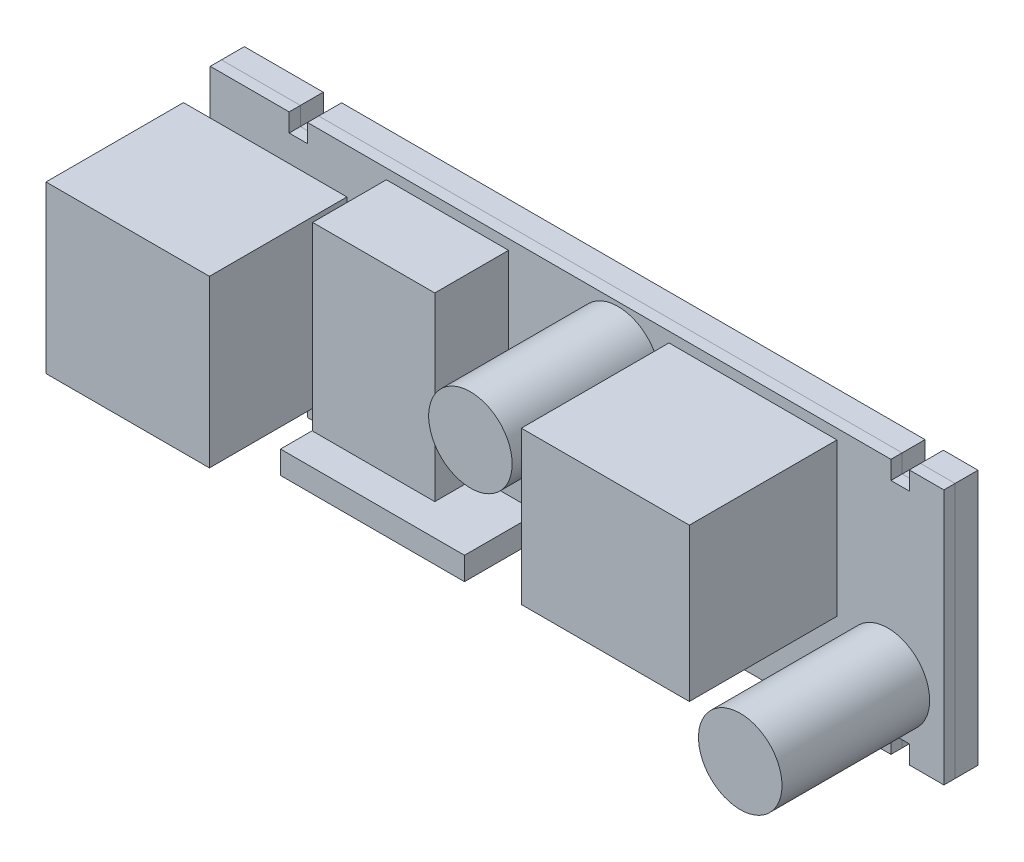
from build123d import *

# Parameters (mm, degrees)
SKETCH1_R                 = 1.375
BOSS_BOARDTHK_DEPTH       = 1.1
SKETCH1_3_R               = 1.375
BOSS_LOWERCLEARANCE_DEPTH = 2.25
SKETCH2_R                 = 4.1
BOSS_EXTRUDE3_DEPTH       = 14.5
BOSS_EXTRUDE3_2_DEPTH     = 14.5
SKETCH2_W                 = 16.5
SKETCH2_H                 = 15
BOSS_EXTRUDE3_3_DEPTH     = 14.5
SKETCH2_4_W               = 12
SKETCH2_4_H               = 17.75
SKETCH2_4_W_2             = 18.07
SKETCH2_4_H_2             = 2.25
BOSS_EXTRUDE4_DEPTH       = 7.25
SKETCH2_5_W               = 16.05
SKETCH2_5_H               = 16.3
BOSS_EXTRUDE5_DEPTH       = 13.5


with BuildPart() as part:
    # Sketch1 → Boss-BoardThk (new body)
    with BuildSketch(Plane.XY):
        Polygon((-36.675, 12.55), (-36.675, -12.55), (-28.925, -12.55), (-28.925, -10.75), (-27.125, -10.75), (-27.125, -12.55), (30.175, -12.55), (30.175, -10.75), (31.975, -10.75), (31.975, -12.55), (35.375, -12.55), (35.375, 12.55), (31.975, 12.55), (31.975, 10.75), (30.175, 10.75), (30.175, 12.55), (-27.125, 12.55), (-27.125, 10.75), (-28.925, 10.75), (-28.925, 12.55), align=None)
        Circle(SKETCH1_R, mode=Mode.SUBTRACT)
    extrude(amount=BOSS_BOARDTHK_DEPTH)

    # Sketch2_4 → Boss-Extrude4 (add)
    with BuildSketch(Plane.XY.offset(1.1)):
        with Locations((-13.375, 2.675)):
            Rectangle(SKETCH2_4_W, SKETCH2_4_H)
        with Locations((-13.49, -10.425)):
            Rectangle(SKETCH2_4_W_2, SKETCH2_4_H_2)
    extrude(amount=BOSS_EXTRUDE4_DEPTH)

    # Sketch2_5 → Boss-Extrude5 (add)
    with BuildSketch(Plane.XY.offset(1.1)):
        with Locations((-31.28, 0)):
            Rectangle(SKETCH2_5_W, SKETCH2_5_H)
    extrude(amount=BOSS_EXTRUDE5_DEPTH)


with BuildPart() as body_2:
    # Sketch1_3 → Boss-LowerClearance (new body)
    with BuildSketch(Plane.XY):
        Polygon((-36.675, 12.55), (-36.675, -12.55), (-28.925, -12.55), (-28.925, -10.75), (-27.125, -10.75), (-27.125, -12.55), (30.175, -12.55), (30.175, -10.75), (31.975, -10.75), (31.975, -12.55), (35.375, -12.55), (35.375, 12.55), (31.975, 12.55), (31.975, 10.75), (30.175, 10.75), (30.175, 12.55), (-27.125, 12.55), (-27.125, 10.75), (-28.925, 10.75), (-28.925, 12.55), align=None)
        Circle(SKETCH1_3_R, mode=Mode.SUBTRACT)
    extrude(amount=-BOSS_LOWERCLEARANCE_DEPTH)


with BuildPart() as body_3:
    # Sketch2 → Boss-Extrude3 (new body)
    with BuildSketch(Plane.XY.offset(1.1)):
        with Locations((29.875, -6.05)):
            Circle(SKETCH2_R)
    extrude(amount=BOSS_EXTRUDE3_DEPTH)


with BuildPart() as body_4:
    # Sketch2 → Boss-Extrude3 2 (new body)
    with BuildSketch(Plane.XY.offset(1.1)):
        with Locations((3.375, 8.05)):
            Circle(SKETCH2_R)
    extrude(amount=BOSS_EXTRUDE3_2_DEPTH)


with BuildPart() as body_5:
    # Sketch2 → Boss-Extrude3 3 (new body)
    with BuildSketch(Plane.XY.offset(1.1)):
        with Locations((16.625, 4.05)):
            Rectangle(SKETCH2_W, SKETCH2_H)
    extrude(amount=BOSS_EXTRUDE3_3_DEPTH)


solid = Compound([part.part, body_2.part, body_3.part, body_4.part, body_5.part])
